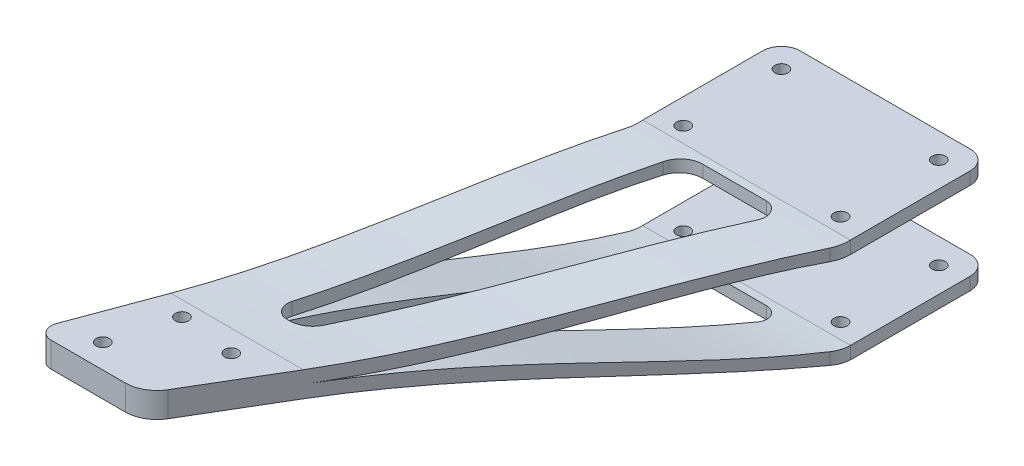
from build123d import *

# Parameters (mm, degrees)
SKETCH1_R           = 2.1
BOSS_EXTRUDE1_DEPTH = 33
SKETCH2_R           = 2.1
CUT_EXTRUDE1_DEPTH  = 34
SKETCH3_W           = 38.075161257
SKETCH3_H           = 25
SKETCH3_W_2         = 6
CUT_EXTRUDE2_DEPTH  = 116.907356637


with BuildPart() as part:
    # Sketch1 → Boss-Extrude1 (new body)
    with BuildSketch(Plane(origin=(0, 0, 0), x_dir=(1, 0, 0), z_dir=(0, 1, 0))):
        with BuildLine():
            Line((75.199480985, 36.1), (100.254955838, 36.1))
            ThreePointArc((100.254955838, 36.1), (104.497596525, 34.342640687), (106.254955838, 30.1))
            Line((106.254955838, 30.1), (106.254955838, -7.975161257))
            ThreePointArc((106.254955838, -7.975161257), (105.898530759, -10.621188988), (104.854663288, -13.07859459))
            Line((104.854663288, -13.07859459), (26.50549073, -145.103433333))
            ThreePointArc((26.50549073, -145.103433333), (22.85379635, -148.690061373), (17.905783281, -150))
            Line((17.905783281, -150), (-5.652400799, -150))
            ThreePointArc((-5.652400799, -150), (-8.935637839, -148.284809519), (-9.40318642, -144.610177269))
            Line((-9.40318642, -144.610177269), (39.631919892, -12.276630222))
            ThreePointArc((39.631919892, -12.276630222), (40.097964538, -10.567060572), (40.254955838, -8.802073396))
            Line((40.254955838, -8.802073396), (40.254955838, 30.1))
            ThreePointArc((40.254955838, 30.1), (42.012315151, 34.342640687), (46.254955838, 36.1))
            Line((46.254955838, 36.1), (75.199480985, 36.1))
        make_face()
        with Locations((48.254955838, 28.1)):
            Circle(SKETCH1_R, mode=Mode.SUBTRACT)
        with Locations((98.254955838, 28.1)):
            Circle(SKETCH1_R, mode=Mode.SUBTRACT)
        with Locations((98.254955838, -3.1)):
            Circle(SKETCH1_R, mode=Mode.SUBTRACT)
        with Locations((48.254955838, -3.1)):
            Circle(SKETCH1_R, mode=Mode.SUBTRACT)
    extrude(amount=BOSS_EXTRUDE1_DEPTH)

    # Sketch2 → Cut-Extrude1 (cut, through all)
    with BuildSketch(Plane(origin=(0, 33, 0), x_dir=(1, 0, 0), z_dir=(0, 1, 0))):
        with Locations((3.111342493, -142.35214503)):
            Circle(SKETCH2_R)
        with Locations((26.535930844, -124.978908669)):
            Circle(SKETCH2_R)
        with Locations((8.772284678, -122.876487522)):
            Circle(SKETCH2_R)
        with BuildLine():
            Line((61.888033254, -10.40841223), (81.971717928, -10.40841223))
            ThreePointArc((81.971717928, -10.40841223), (85.447742477, -12.429207002), (85.411600907, -16.449785563))
            Line((85.411600907, -16.449785563), (33.963202835, -103.144593402))
            ThreePointArc((33.963202835, -103.144593402), (31.041847331, -106.013895834), (27.083436875, -107.061846735))
            Line((27.083436875, -107.061846735), (26.254627087, -107.061846735))
            ThreePointArc((26.254627087, -107.061846735), (22.971390047, -105.346656254), (22.503841465, -101.672024005))
            Line((22.503841465, -101.672024005), (54.386462011, -15.628766769))
            ThreePointArc((54.386462011, -15.628766769), (57.318414216, -11.84193815), (61.888033254, -10.40841223))
        make_face()
    extrude(amount=-CUT_EXTRUDE1_DEPTH, mode=Mode.SUBTRACT)

    # Sketch3 → Cut-Extrude2 (cut, through all)
    with BuildSketch(Plane(origin=(106.254955838, 0, 0), x_dir=(0, 0, -1), z_dir=(1, 0, 0))):
        with BuildLine():
            add(Edge.make_bspline(
                [(-118.095376148, 12.5), (-78.389699538, 12.5), (-43.509505402, 1.928802936), (-7.975161257, 0)],
                knots=[0, 0, 0, 0, 1, 1, 1, 1], degree=3))
            Line((-7.975161257, 0), (-150, 0))
            Line((-150, 0), (-150, 12.5))
            Line((-150, 12.5), (-118.095376148, 12.5))
        make_face()
        with BuildLine():
            Line((-118.095376148, 20.5), (-150, 20.5))
            Line((-150, 20.5), (-150, 33))
            Line((-150, 33), (-7.975161257, 33))
            add(Edge.make_bspline(
                [(-118.095376148, 20.5), (-78.389699538, 20.5), (-43.509505402, 31.071197064), (-7.975161257, 33)],
                knots=[0, 0, 0, 0, 1, 1, 1, 1], degree=3))
        make_face()
        with BuildLine():
            Line((-7.975161257, 4), (-7.975161257, 29))
            add(Edge.make_bspline(
                [(-7.975161257, 29), (-41.026862303, 28.801538184), (-72.42191123, 16.604183052), (-116.948199363, 16.5)],
                knots=[0, 0, 0, 0, 0.991506458, 0.991506458, 0.991506458, 0.991506458], degree=3))
            add(Edge.make_bspline(
                [(-7.975161257, 4), (-41.026862303, 4.198461816), (-72.42191123, 16.395816948), (-116.948199363, 16.5)],
                knots=[0, 0, 0, 0, 0.991506458, 0.991506458, 0.991506458, 0.991506458], degree=3))
        make_face()
        with Locations((11.062419372, 16.5)):
            Rectangle(SKETCH3_W, SKETCH3_H)
        with Locations((33.1, 16.5)):
            Rectangle(SKETCH3_W_2, SKETCH3_H)
    extrude(amount=-CUT_EXTRUDE2_DEPTH, mode=Mode.SUBTRACT)


solid = part.part
